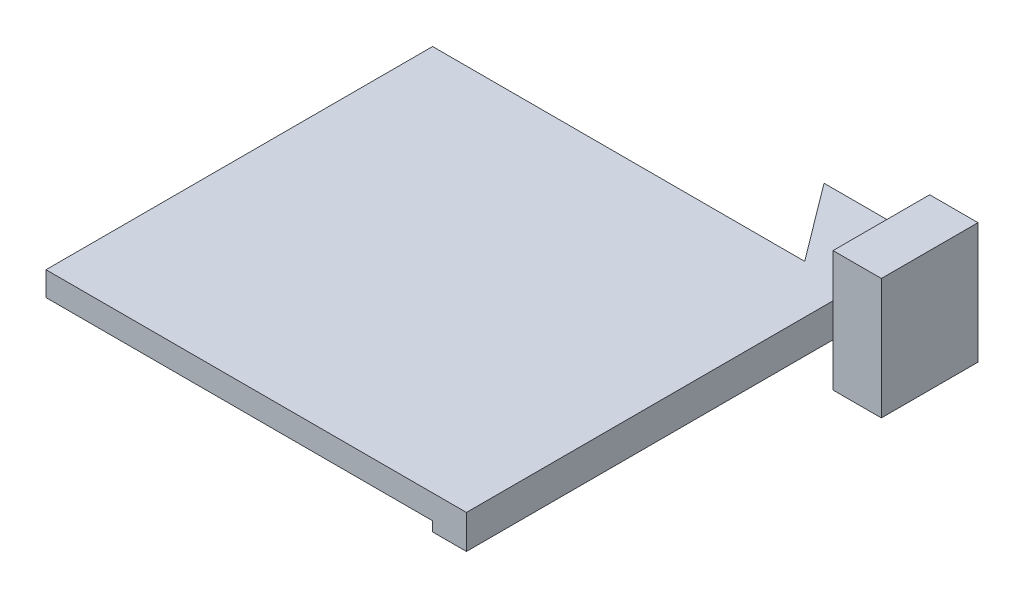
from build123d import *

# Parameters (mm, degrees)
SKETCH1_W           = 7
SKETCH1_H           = 7
BOSS_EXTRUDE1_DEPTH = 100
SKETCH3_W           = 80
SKETCH3_H           = 80
BOSS_EXTRUDE2_DEPTH = 5
BOSS_EXTRUDE5_DEPTH = 7
SKETCH11_W          = 20
SKETCH11_H          = 25
BOSS_EXTRUDE6_DEPTH = 10


with BuildPart() as part:
    # Sketch1 → Boss-Extrude1 (new body)
    with BuildSketch(Plane.XY):
        Rectangle(SKETCH1_W, SKETCH1_H)
    extrude(amount=BOSS_EXTRUDE1_DEPTH)

    # Sketch3 → Boss-Extrude2 (add)
    with BuildSketch(Plane(origin=(0, 3.5, 0), x_dir=(1, 0, 0), z_dir=(0, 1, 0))):
        with Locations((-43.5, -60)):
            Rectangle(SKETCH3_W, SKETCH3_H)
    extrude(amount=-BOSS_EXTRUDE2_DEPTH)

    # Sketch8 → Boss-Extrude5 (add)
    with BuildSketch(Plane.XZ.offset(3.5)):
        Polygon((-3.5, 20), (-6.5, 20), (-18.5, 4), (-3.5, 4), align=None)
    extrude(amount=-BOSS_EXTRUDE5_DEPTH)

    # Sketch11 → Boss-Extrude6 (add)
    with BuildSketch(Plane(origin=(3.5, 0, 0), x_dir=(0, 0, -1), z_dir=(1, 0, 0))):
        with Locations((-14.137320527, 0)):
            Rectangle(SKETCH11_W, SKETCH11_H)
    extrude(amount=BOSS_EXTRUDE6_DEPTH)


solid = part.part
